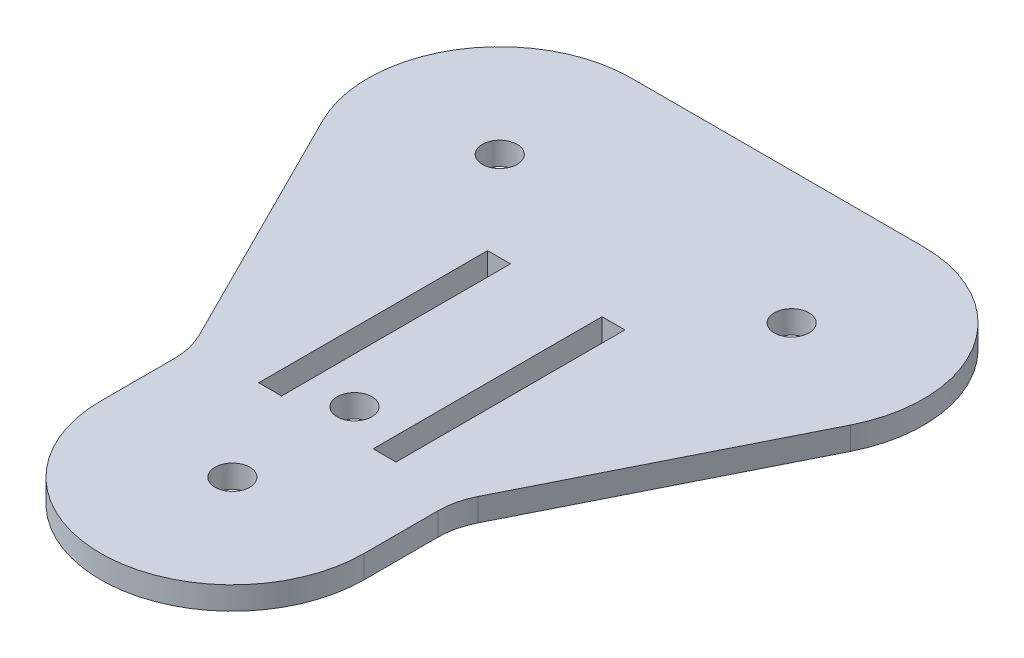
from build123d import *

# Parameters (mm, degrees)
SKETCH1_R           = 2.413
BOSS_EXTRUDE1_DEPTH = 3.175
FILLET1_R           = 10
CUT_EXTRUDE1_REACH  = 72.275
SKETCH2_W           = 3.175
SKETCH2_H           = 31.75


with BuildPart() as part:
    # Sketch1 → Boss-Extrude1 (new body)
    with BuildSketch(Plane(origin=(0, 0, 0), x_dir=(1, 0, 0), z_dir=(0, 1, 0))):
        with BuildLine():
            Line((20.2438, 58.6843124), (-20.2438, 58.6843124))
            ThreePointArc((-20.2438, 58.6843124), (-35.804843833, 50.003854168), (-36.593688296, 32.202894511))
            Line((-36.593688296, 32.202894511), (-18.288, -4.325934222))
            Line((-18.288, -4.325934222), (-18.288, -16.933333333))
            ThreePointArc((-18.288, -16.933333333), (0, -35.221333333), (18.288, -16.933333333))
            Line((18.288, -16.933333333), (18.288, -4.325934222))
            Line((18.288, -4.325934222), (36.593688296, 32.202894511))
            ThreePointArc((36.593688296, 32.202894511), (35.804843833, 50.003854168), (20.2438, 58.6843124))
        make_face()
        with Locations((-20.2438, 40.3963124)):
            Circle(SKETCH1_R, mode=Mode.SUBTRACT)
        with Locations((20.2438, 40.3963124)):
            Circle(SKETCH1_R, mode=Mode.SUBTRACT)
        Circle(SKETCH1_R, mode=Mode.SUBTRACT)
        with Locations((0, -16.933333333)):
            Circle(SKETCH1_R, mode=Mode.SUBTRACT)
    extrude(amount=BOSS_EXTRUDE1_DEPTH)

    # Fillet1
    fillet1_edges = [part.edges().sort_by_distance(p)[0] for p in [
        (18.288, 1.5875, 4.325934222),
        (-18.288, 1.5875, 4.325934222),
    ]]
    fillet(fillet1_edges, radius=FILLET1_R)

    # Sketch2 → Cut-Extrude1 (cut, up to next)
    with BuildSketch(Plane(origin=(0, 3.175, 0), x_dir=(1, 0, 0), z_dir=(0, 1, 0)), mode=Mode.PRIVATE) as cut_extrude1_sk1:
        with Locations((7.9375, 12.1134886)):
            Rectangle(SKETCH2_W, SKETCH2_H)
    cut_extrude1_tool1 = extrude(cut_extrude1_sk1.sketch, amount=-CUT_EXTRUDE1_REACH, mode=Mode.PRIVATE) & part.part
    # Sketch2 → Cut-Extrude1 (cut, up to next)
    with BuildSketch(Plane(origin=(0, 3.175, 0), x_dir=(1, 0, 0), z_dir=(0, 1, 0)), mode=Mode.PRIVATE) as cut_extrude1_sk2:
        with Locations((-7.9375, 12.1134886)):
            Rectangle(SKETCH2_W, SKETCH2_H)
    cut_extrude1_tool2 = extrude(cut_extrude1_sk2.sketch, amount=-CUT_EXTRUDE1_REACH, mode=Mode.PRIVATE) & part.part
    add(cut_extrude1_tool1.solids().sort_by_distance((7.9375, 3.175, -12.113489))[0], mode=Mode.SUBTRACT)
    add(cut_extrude1_tool2.solids().sort_by_distance((-7.9375, 3.175, -12.113489))[0], mode=Mode.SUBTRACT)


solid = part.part
